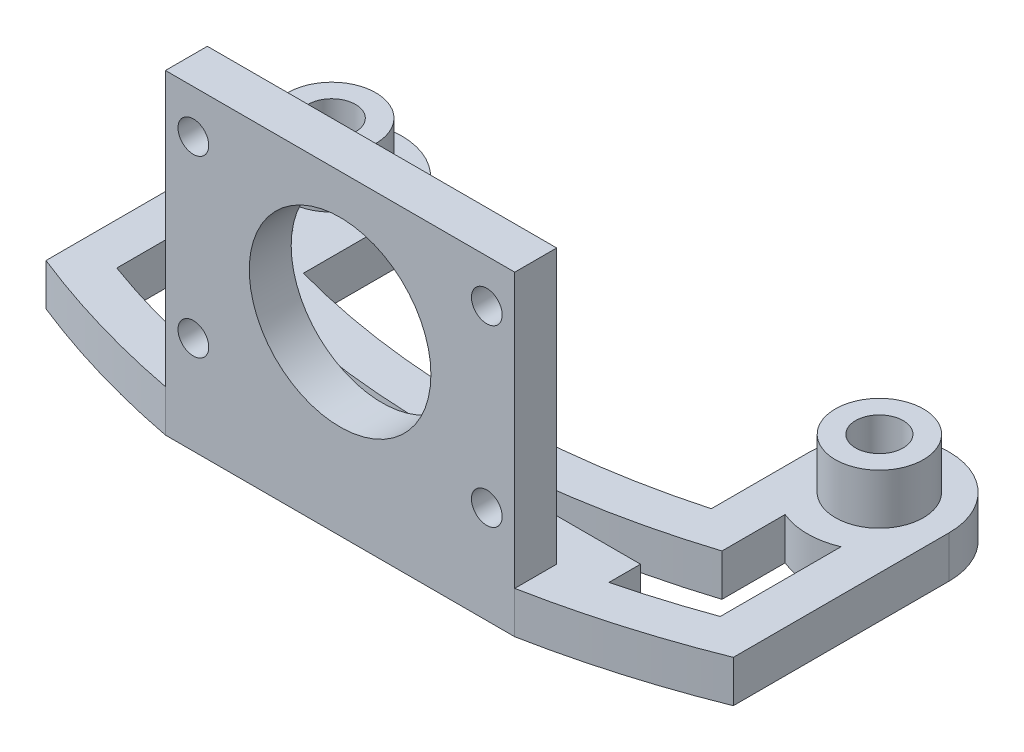
from build123d import *

# Parameters (mm, degrees)
SKETCH1_R           = 1.7
BOSS_EXTRUDE2_DEPTH = 3
SKETCH1_5_R         = 3.15
SKETCH1_5_R_2       = 1.7
SKETCH1_5_W         = 25
SKETCH1_5_H         = 3
BOSS_EXTRUDE3_DEPTH = 3.6
BOSS_EXTRUDE4_START = 3.6
SKETCH1_7_W         = 25
SKETCH1_7_H         = 3
BOSS_EXTRUDE4_DEPTH = 16
CUT_EXTRUDE1_REACH  = 26
SKETCH2_R           = 1.1
SKETCH2_R_2         = 6.5
CUT_EXTRUDE2_REACH  = 5


with BuildPart() as part:
    # Sketch1 → Boss-Extrude2 (new body)
    with BuildSketch(Plane(origin=(0, 0, 0), x_dir=(1, 0, 0), z_dir=(0, 1, 0))):
        with BuildLine():
            ThreePointArc((24.595917942, -46), (19.595917942, -41), (14.595917942, -46))
            Line((14.595917942, -46), (14.595917942, -53.027909439))
            ThreePointArc((14.595917942, -53.027909439), (0, -55), (-14.595917942, -53.027909439))
            Line((-14.595917942, -53.027909439), (-14.595917942, -46))
            ThreePointArc((-14.595917942, -46), (-19.595917942, -41), (-24.595917942, -46))
            Line((-24.595917942, -46), (-24.595917942, -61.451532288))
            ThreePointArc((-24.595917942, -61.451532288), (-18.632624286, -63.514370911), (-12.5, -65))
            Line((-12.5, -65), (12.5, -65))
            ThreePointArc((12.5, -65), (18.632624286, -63.514370911), (24.595917942, -61.451532288))
            Line((24.595917942, -61.451532288), (24.595917942, -46))
        make_face()
        with Locations((-19.595917942, -46)):
            Circle(SKETCH1_R, mode=Mode.SUBTRACT)
        with Locations((19.595917942, -46)):
            Circle(SKETCH1_R, mode=Mode.SUBTRACT)
    extrude(amount=-BOSS_EXTRUDE2_DEPTH)

    # Sketch1_5 → Boss-Extrude3 (add)
    with BuildSketch(Plane(origin=(0, 0, 0), x_dir=(1, 0, 0), z_dir=(0, 1, 0))):
        with Locations((-19.595917942, -46)):
            Circle(SKETCH1_5_R)
        with Locations((-19.595917942, -46)):
            Circle(SKETCH1_5_R_2, mode=Mode.SUBTRACT)
        with Locations((19.595917942, -46)):
            Circle(SKETCH1_5_R)
        with Locations((19.595917942, -46)):
            Circle(SKETCH1_5_R_2, mode=Mode.SUBTRACT)
        with Locations((0, -63.5)):
            Rectangle(SKETCH1_5_W, SKETCH1_5_H)
    extrude(amount=BOSS_EXTRUDE3_DEPTH)

    # Sketch1_7 → Boss-Extrude4 (add)
    with BuildSketch(Plane(origin=(0, 0, 0), x_dir=(1, 0, 0), z_dir=(0, 1, 0)).offset(BOSS_EXTRUDE4_START)):
        with Locations((0, -63.5)):
            Rectangle(SKETCH1_7_W, SKETCH1_7_H)
    extrude(amount=BOSS_EXTRUDE4_DEPTH)

    # Sketch2 → Cut-Extrude1 (cut, up to next)
    with BuildSketch(Plane.XY.offset(65), mode=Mode.PRIVATE) as cut_extrude1_sk1:
        with Locations((-10.5, 4)):
            Circle(SKETCH2_R)
    cut_extrude1_tool1 = extrude(cut_extrude1_sk1.sketch, amount=-CUT_EXTRUDE1_REACH, mode=Mode.PRIVATE) & part.part
    add(cut_extrude1_tool1.solids().sort_by_distance((-10.5, 4, 65))[0], mode=Mode.SUBTRACT)
    # Sketch2 → Cut-Extrude1 (cut, up to next)
    with BuildSketch(Plane.XY.offset(65), mode=Mode.PRIVATE) as cut_extrude1_sk2:
        with Locations((-10.5, 16.5)):
            Circle(SKETCH2_R)
    cut_extrude1_tool2 = extrude(cut_extrude1_sk2.sketch, amount=-CUT_EXTRUDE1_REACH, mode=Mode.PRIVATE) & part.part
    add(cut_extrude1_tool2.solids().sort_by_distance((-10.5, 16.5, 65))[0], mode=Mode.SUBTRACT)
    # Sketch2 → Cut-Extrude1 (cut, up to next)
    with BuildSketch(Plane.XY.offset(65), mode=Mode.PRIVATE) as cut_extrude1_sk3:
        with Locations((10.5, 4)):
            Circle(SKETCH2_R)
    cut_extrude1_tool3 = extrude(cut_extrude1_sk3.sketch, amount=-CUT_EXTRUDE1_REACH, mode=Mode.PRIVATE) & part.part
    add(cut_extrude1_tool3.solids().sort_by_distance((10.5, 4, 65))[0], mode=Mode.SUBTRACT)
    # Sketch2 → Cut-Extrude1 (cut, up to next)
    with BuildSketch(Plane.XY.offset(65), mode=Mode.PRIVATE) as cut_extrude1_sk4:
        with Locations((10.5, 16.5)):
            Circle(SKETCH2_R)
    cut_extrude1_tool4 = extrude(cut_extrude1_sk4.sketch, amount=-CUT_EXTRUDE1_REACH, mode=Mode.PRIVATE) & part.part
    add(cut_extrude1_tool4.solids().sort_by_distance((10.5, 16.5, 65))[0], mode=Mode.SUBTRACT)
    # Sketch2 → Cut-Extrude1 (cut, up to next)
    with BuildSketch(Plane.XY.offset(65), mode=Mode.PRIVATE) as cut_extrude1_sk5:
        with Locations((0, 10.25)):
            Circle(SKETCH2_R_2)
    cut_extrude1_tool5 = extrude(cut_extrude1_sk5.sketch, amount=-CUT_EXTRUDE1_REACH, mode=Mode.PRIVATE) & part.part
    add(cut_extrude1_tool5.solids().sort_by_distance((0, 10.25, 65))[0], mode=Mode.SUBTRACT)

    # Sketch3 → Cut-Extrude2 (cut, up to next)
    with BuildSketch(Plane(origin=(0, 0, 0), x_dir=(1, 0, 0), z_dir=(0, 1, 0)), mode=Mode.PRIVATE) as cut_extrude2_sk1:
        with BuildLine():
            Line((-15.5, -61.260541388), (-15.5, -59))
            Line((-15.5, -59), (15.5, -59))
            Line((15.5, -59), (15.5, -61.260541388))
            ThreePointArc((15.5, -61.260541388), (18.571620144, -60.400321658), (21.595917942, -59.386195866))
            Line((21.595917942, -59.386195866), (21.595917942, -50.745787606))
            ThreePointArc((21.595917942, -50.745787606), (19.595917942, -51.15), (17.595917942, -50.745787606))
            Line((17.595917942, -50.745787606), (17.595917942, -55.266478735))
            ThreePointArc((17.595917942, -55.266478735), (0, -58), (-17.595917942, -55.266478735))
            Line((-17.595917942, -55.266478735), (-17.595917942, -50.745787606))
            ThreePointArc((-17.595917942, -50.745787606), (-19.595917942, -51.15), (-21.595917942, -50.745787606))
            Line((-21.595917942, -50.745787606), (-21.595917942, -59.386195866))
            ThreePointArc((-21.595917942, -59.386195866), (-18.571620144, -60.400321658), (-15.5, -61.260541388))
        make_face()
    cut_extrude2_tool1 = extrude(cut_extrude2_sk1.sketch, amount=-CUT_EXTRUDE2_REACH, mode=Mode.PRIVATE) & part.part
    add(cut_extrude2_tool1.solids().sort_by_distance((-18.040451, 0, 53.006133))[0], mode=Mode.SUBTRACT)


solid = part.part
